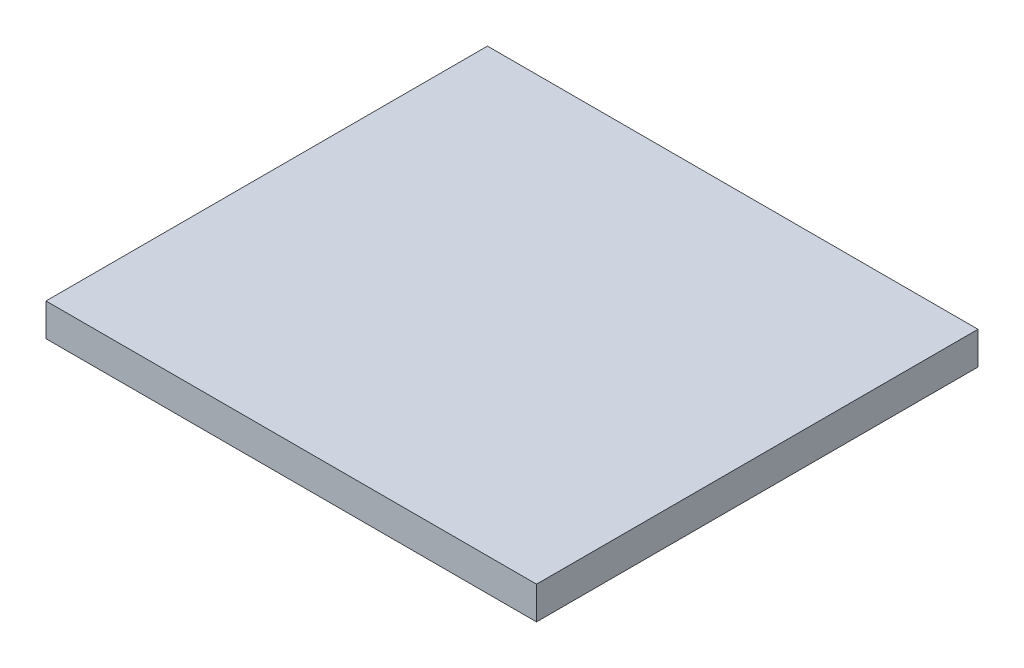
from build123d import *

# Parameters (mm, degrees)
SKETCH1_W           = 150
SKETCH1_H           = 10
BOSS_EXTRUDE1_DEPTH = 135


with BuildPart() as part:
    # Sketch1 → Boss-Extrude1 (new body)
    with BuildSketch(Plane.XY):
        Rectangle(SKETCH1_W, SKETCH1_H)
    extrude(amount=BOSS_EXTRUDE1_DEPTH)


solid = part.part
